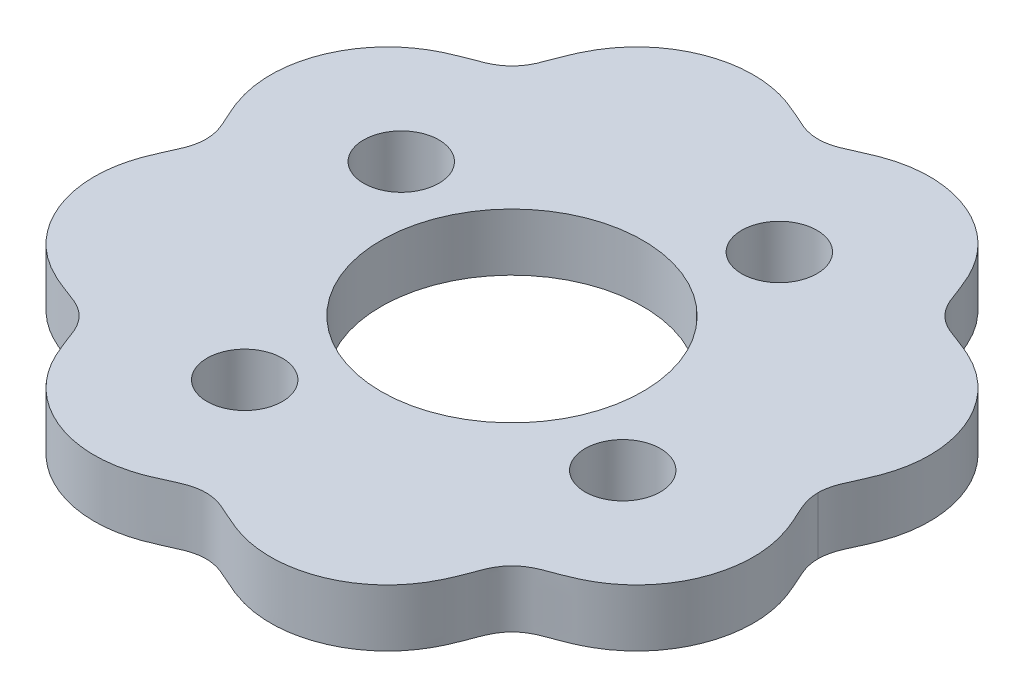
from build123d import *

# Parameters (mm, degrees)
BOSS_EXTRUDE1_DEPTH = 7
SKETCH3_R           = 16
SKETCH3_R_2         = 4.5
CUT_EXTRUDE1_DEPTH  = 7
CUT_EXTRUDE2_DEPTH  = 7
SKETCH5_R           = 4.6
SKETCH5_R_2         = 4.5
CUT_EXTRUDE3_DEPTH  = 7


with BuildPart() as part:
    # Sketch2 → Boss-Extrude1 (new body)
    with BuildSketch(Plane(origin=(0, 0, 0), x_dir=(1, 0, 0), z_dir=(0, 1, 0))):
        with BuildLine():
            add(Edge.make_bspline(
                [(37.500000178, 0), (37.500001348, -0.153650042), (37.516723117, -0.585734713), (37.60134551, -1.155885936), (37.799451038, -1.845132779), (38.055257689, -2.50061582), (38.284413658, -3.01884437), (38.547573645, -3.586057627), (38.834335204, -4.207231283), (39.213023964, -5.071386775), (39.642902809, -6.195484546), (40.034770345, -7.545626157), (40.309114863, -9.129071904), (40.402480997, -10.733442687), (40.292330227, -12.739242447), (39.800709206, -15.115411572), (38.875008006, -17.372282299), (37.550500891, -19.416826213), (36.201869244, -20.937061223), (34.991297456, -22.022332107), (33.664442598, -22.961820777), (32.418877976, -23.648429526), (31.307176029, -24.144813461), (30.415442254, -24.492540623), (29.760772524, -24.733252947), (29.159260868, -24.953726937), (28.615153012, -25.166050116), (27.968227921, -25.455751973), (27.242450172, -25.869161743), (26.486758972, -26.478530797), (25.788934233, -27.338578085), (25.333439826, -28.199550113), (25.02084924, -28.978917238), (24.756184284, -29.69717513), (24.520071708, -30.342148991), (24.176798097, -31.229963234), (23.685673389, -32.343953643), (23.006023391, -33.593318677), (22.074382722, -34.925670234), (20.99628636, -36.142619362), (19.483992231, -37.500137581), (17.436434568, -38.843473511), (15.165772212, -39.787003781), (12.765640508, -40.290729235), (10.727941267, -40.403684264), (9.098120231, -40.306732746), (7.490297544, -40.023060283), (6.12050869, -39.618509318), (4.980859334, -39.175936442), (3.981084292, -38.733166074), (3.107747272, -38.323212218), (2.16284156, -37.896233325), (1.102684883, -37.568652762), (-4e-09, -37.451718585), (-1.102684874, -37.568652759), (-2.162841573, -37.896233332), (-3.107747248, -38.323212203), (-3.981084328, -38.733166098), (-4.980859269, -39.175936398), (-6.120508811, -39.6185094), (-7.490297349, -40.023060149), (-9.098120503, -40.306732933), (-10.727940878, -40.403683996), (-12.765641194, -40.290729708), (-15.165770912, -39.787002885), (-17.436436591, -38.843474905), (-19.48398961, -37.500135775), (-20.996290415, -36.142622155), (-22.074374394, -34.925664496), (-23.006039129, -33.59332952), (-23.685647307, -32.343935674), (-24.176838549, -31.229991103), (-24.570729586, -30.210893235), (-24.899588849, -29.300399238), (-25.267416458, -28.324512461), (-25.788900803, -27.338555053), (-26.486780724, -26.478545782), (-27.242436428, -25.869152274), (-27.968236735, -25.455758045), (-28.615147496, -25.166046316), (-29.159264206, -24.953729236), (-29.760770668, -24.733251668), (-30.415443148, -24.492541238), (-31.307175489, -24.144813089), (-32.41887831, -23.648429756), (-33.6644424, -22.96182064), (-34.99129756, -22.022332179), (-36.201869193, -20.937061188), (-37.550500924, -19.416826235), (-38.875007981, -17.372282282), (-39.800709222, -15.115411584), (-40.292330218, -12.739242441), (-40.402481002, -10.733442691), (-40.309114859, -9.129071901), (-40.034770347, -7.545626159), (-39.642902807, -6.195484545), (-39.213023965, -5.071386776), (-38.834335204, -4.207231283), (-38.547573646, -3.586057627), (-38.284413658, -3.01884437), (-38.055257689, -2.50061582), (-37.799451038, -1.845132779), (-37.60134551, -1.155885936), (-37.516723117, -0.585734713), (-37.500001348, -0.153650042), (-37.500000178, 0)],
                knots=[0.119900748, 0.119900748, 0.119900748, 0.119900748, 0.119900748, 0.123359436, 0.129627259, 0.132815238, 0.136003217, 0.139191195, 0.142379174, 0.14689104, 0.151402906, 0.160426638, 0.169450869, 0.1784751, 0.187499512, 0.196523925, 0.214572937, 0.232831382, 0.241960244, 0.251089107, 0.260218415, 0.269347723, 0.278476117, 0.283040314, 0.287604511, 0.290890352, 0.294176194, 0.297462035, 0.300747877, 0.306837966, 0.312927068, 0.319161334, 0.325493528, 0.328659626, 0.331825723, 0.336390118, 0.340954513, 0.350083302, 0.35921236, 0.368341418, 0.377470301, 0.386599184, 0.404857643, 0.423193135, 0.432360527, 0.441527919, 0.450695565, 0.459863212, 0.469030281, 0.473613816, 0.47819735, 0.484472892, 0.490748434, 0.496943117, 0.503056883, 0.509251566, 0.515527108, 0.52180265, 0.526386184, 0.530969719, 0.540136788, 0.549304435, 0.558472081, 0.567639473, 0.576806865, 0.595142357, 0.613400816, 0.622529699, 0.631658582, 0.64078764, 0.649916698, 0.659045487, 0.663609882, 0.668174277, 0.674506472, 0.680838666, 0.687072932, 0.693162034, 0.699252123, 0.702537965, 0.705823806, 0.709109648, 0.712395489, 0.716959686, 0.721523883, 0.730652277, 0.739781585, 0.748910893, 0.758039756, 0.767168618, 0.785427063, 0.803476075, 0.812500488, 0.8215249, 0.830549131, 0.839573362, 0.848597094, 0.85310896, 0.857620826, 0.860808805, 0.863996783, 0.867184762, 0.870372741, 0.876640564, 0.880099252, 0.880099252, 0.880099252, 0.880099252, 0.880099252], degree=4))
            add(Edge.make_bspline(
                [(37.500000178, 0), (37.500001348, 0.153650042), (37.516723117, 0.585734713), (37.60134551, 1.155885936), (37.799451038, 1.845132779), (38.055257689, 2.50061582), (38.284413658, 3.018844371), (38.547573645, 3.586057627), (38.834335204, 4.207231284), (39.213023964, 5.071386775), (39.642902809, 6.195484546), (40.034770345, 7.545626157), (40.309114863, 9.129071904), (40.402480997, 10.733442688), (40.292330227, 12.739242447), (39.800709205, 15.115411572), (38.875008006, 17.3722823), (37.550500891, 19.416826213), (36.201869244, 20.937061223), (34.991297456, 22.022332107), (33.664442598, 22.961820777), (32.418877976, 23.648429526), (31.307176029, 24.144813461), (30.415442254, 24.492540623), (29.760772524, 24.733252947), (29.159260868, 24.953726937), (28.615153012, 25.166050117), (27.968227921, 25.455751974), (27.242450172, 25.869161744), (26.486758972, 26.478530797), (25.788934233, 27.338578085), (25.333439826, 28.199550113), (25.02084924, 28.978917238), (24.756184284, 29.69717513), (24.520071708, 30.342148991), (24.176798097, 31.229963234), (23.685673389, 32.343953643), (23.006023391, 33.593318677), (22.074382722, 34.925670234), (20.99628636, 36.142619362), (19.483992231, 37.500137582), (17.436434568, 38.843473511), (15.165772212, 39.787003781), (12.765640508, 40.290729235), (10.727941267, 40.403684265), (9.098120231, 40.306732746), (7.490297544, 40.023060283), (6.12050869, 39.618509318), (4.980859334, 39.175936443), (3.981084292, 38.733166074), (3.107747271, 38.323212218), (2.162841559, 37.896233325), (1.102684882, 37.568652762), (-4e-09, 37.451718586), (-1.102684874, 37.568652759), (-2.162841573, 37.896233332), (-3.107747248, 38.323212203), (-3.981084328, 38.733166098), (-4.980859269, 39.175936399), (-6.120508811, 39.6185094), (-7.490297349, 40.023060149), (-9.098120503, 40.306732933), (-10.727940878, 40.403683996), (-12.765641194, 40.290729708), (-15.165770912, 39.787002885), (-17.436436591, 38.843474905), (-19.48398961, 37.500135776), (-20.996290415, 36.142622155), (-22.074374394, 34.925664496), (-23.006039129, 33.59332952), (-23.685647307, 32.343935674), (-24.176838549, 31.229991103), (-24.570729586, 30.210893235), (-24.899588849, 29.300399238), (-25.267416458, 28.324512461), (-25.788900803, 27.338555053), (-26.486780724, 26.478545782), (-27.242436428, 25.869152274), (-27.968236735, 25.455758045), (-28.615147496, 25.166046316), (-29.159264206, 24.953729236), (-29.760770668, 24.733251668), (-30.415443148, 24.492541238), (-31.307175489, 24.144813089), (-32.418878311, 23.648429756), (-33.6644424, 22.96182064), (-34.99129756, 22.022332179), (-36.201869193, 20.937061188), (-37.550500924, 19.416826235), (-38.875007981, 17.372282282), (-39.800709222, 15.115411584), (-40.292330218, 12.739242441), (-40.402481002, 10.733442691), (-40.309114859, 9.129071901), (-40.034770347, 7.545626159), (-39.642902807, 6.195484545), (-39.213023965, 5.071386776), (-38.834335204, 4.207231283), (-38.547573646, 3.586057627), (-38.284413658, 3.01884437), (-38.055257689, 2.50061582), (-37.799451038, 1.845132779), (-37.60134551, 1.155885936), (-37.516723117, 0.585734713), (-37.500001348, 0.153650042), (-37.500000178, 0)],
                knots=[0.119900748, 0.119900748, 0.119900748, 0.119900748, 0.119900748, 0.123359436, 0.129627259, 0.132815238, 0.136003217, 0.139191195, 0.142379174, 0.14689104, 0.151402906, 0.160426638, 0.169450869, 0.1784751, 0.187499512, 0.196523925, 0.214572937, 0.232831382, 0.241960244, 0.251089107, 0.260218415, 0.269347723, 0.278476117, 0.283040314, 0.287604511, 0.290890352, 0.294176194, 0.297462035, 0.300747877, 0.306837966, 0.312927068, 0.319161334, 0.325493528, 0.328659626, 0.331825723, 0.336390118, 0.340954513, 0.350083302, 0.35921236, 0.368341418, 0.377470301, 0.386599184, 0.404857643, 0.423193135, 0.432360527, 0.441527919, 0.450695565, 0.459863212, 0.469030281, 0.473613816, 0.47819735, 0.484472892, 0.490748434, 0.496943117, 0.503056883, 0.509251566, 0.515527108, 0.52180265, 0.526386184, 0.530969719, 0.540136788, 0.549304435, 0.558472081, 0.567639473, 0.576806865, 0.595142357, 0.613400816, 0.622529699, 0.631658582, 0.64078764, 0.649916698, 0.659045487, 0.663609882, 0.668174277, 0.674506472, 0.680838666, 0.687072932, 0.693162034, 0.699252123, 0.702537965, 0.705823806, 0.709109648, 0.712395489, 0.716959686, 0.721523883, 0.730652277, 0.739781585, 0.748910893, 0.758039756, 0.767168618, 0.785427063, 0.803476075, 0.812500488, 0.8215249, 0.830549131, 0.839573362, 0.848597094, 0.85310896, 0.857620826, 0.860808805, 0.863996783, 0.867184762, 0.870372741, 0.876640564, 0.880099252, 0.880099252, 0.880099252, 0.880099252, 0.880099252], degree=4))
        make_face()
    extrude(amount=BOSS_EXTRUDE1_DEPTH)

    # Sketch3 → Cut-Extrude1 (cut)
    with BuildSketch(Plane(origin=(0, 7, 0), x_dir=(1, 0, 0), z_dir=(0, 1, 0))):
        with Locations(Location((0, 0, 0), (0, 0, 270))):
            Circle(SKETCH3_R)
        with Locations(Location((23.096990508, -9.567080508, 0), (0, 0, 270))):
            Circle(SKETCH3_R_2)
        with Locations(Location((-9.567080508, -23.096990508, 0), (0, 0, 270))):
            Circle(SKETCH3_R_2)
        with Locations(Location((-23.096990508, 9.567080508, 0), (0, 0, 270))):
            Circle(SKETCH3_R_2)
        with Locations(Location((9.567080508, 23.096990508, 0), (0, 0, 270))):
            Circle(SKETCH3_R_2)
    extrude(amount=-CUT_EXTRUDE1_DEPTH, mode=Mode.SUBTRACT)

    # Sketch4 → Cut-Extrude2 (cut)
    with BuildSketch(Plane.XZ):
        with BuildLine():
            add(Edge.make_bspline(
                [(37.600000178, -7.62e-07), (37.600005173, 0.655543434), (37.727246294, 1.285292151), (38.148613998, 2.510955716), (38.436102386, 3.105161712), (38.985288009, 4.298020071), (39.25007046, 4.89726072), (39.708668965, 6.116079685), (39.903757651, 6.735293288), (40.210295805, 7.997689961), (40.322350501, 8.640699582), (40.423535505, 9.624385479), (40.446121573, 9.955473947), (40.468001099, 10.624326117), (40.467132418, 10.962202585), (40.404154621, 12.633267942), (40.171207894, 13.940406977), (39.653355411, 15.537439287), (39.53840444, 15.854111127), (39.288969244, 16.474140513), (39.154125231, 16.778652945), (38.719700075, 17.675947604), (38.390382228, 18.252572177), (37.651152224, 19.362029827), (37.237638616, 19.898295795), (36.350233191, 20.896017325), (35.875310831, 21.360215751), (34.86364689, 22.219976378), (34.326804277, 22.615426405), (33.190062483, 23.336316439), (32.60031159, 23.654622118), (31.388326763, 24.220411489), (30.765097907, 24.46709151), (29.82114865, 24.818166657), (29.504943402, 24.932139267), (28.877738152, 25.170299043), (28.566999308, 25.294998698), (27.963605007, 25.579884088), (27.671054253, 25.740275293), (27.252684988, 26.021005802), (27.116605528, 26.121209448), (26.852062793, 26.336562421), (26.722665603, 26.452707189), (26.356285675, 26.816433091), (26.140022275, 27.07952826), (25.757076777, 27.642229352), (25.590264073, 27.942868865), (25.294527671, 28.566753755), (25.165960187, 28.88852981), (24.920043824, 29.537797739), (24.802144961, 29.865009399), (24.438030972, 30.841336769), (24.180422964, 31.484647868), (23.587360405, 32.731607676), (23.25304691, 33.335837747), (22.68412998, 34.207819134), (22.483367041, 34.492811998), (22.058499308, 35.050905177), (21.833191694, 35.325295896), (20.664259321, 36.645203337), (19.595247471, 37.543032975), (18.094714825, 38.471318944), (17.786587006, 38.646710961), (17.16359185, 38.972125312), (16.847523582, 39.122917749), (15.885856655, 39.540202403), (15.22687273, 39.771802315), (13.87261568, 40.140404542), (13.173528063, 40.277153852), (11.782084832, 40.445055871), (11.084941822, 40.478018046), (10.037091008, 40.450827085), (9.687449992, 40.428942237), (8.987437718, 40.358977003), (8.635705971, 40.310604168), (7.593654297, 40.127900907), (6.914470746, 39.955864647), (5.583322024, 39.523679687), (4.931756901, 39.262235939), (3.965705794, 38.833500579), (3.645753433, 38.684780069), (3.005286176, 38.389391142), (2.68471998, 38.242500373), (2.031257787, 37.978515382), (1.696459255, 37.861664089), (1.010367338, 37.687113144), (0.664117722, 37.630625011), (-0.035741815, 37.588381702), (-0.393307149, 37.603289467), (-1.091614861, 37.702477523), (-1.432710085, 37.785974847), (-2.438166569, 38.111475608), (-3.083100648, 38.4262163), (-4.379716439, 39.022574646), (-5.031837648, 39.307994347), (-7.027326378, 40.033339578), (-8.409077537, 40.344832204), (-10.21846616, 40.459155192), (-10.584845551, 40.468254818), (-11.309896166, 40.458614645), (-11.670551949, 40.440062156), (-12.747048154, 40.344216969), (-13.457448828, 40.226967163), (-14.86370086, 39.885597037), (-15.562456431, 39.659406696), (-16.900219943, 39.113501325), (-17.544817785, 38.792942013), (-18.475327327, 38.240768871), (-18.779405529, 38.044768985), (-19.375039214, 37.628219448), (-19.66690843, 37.407240978), (-20.508686277, 36.71835058), (-21.030063876, 36.221285174), (-21.994225641, 35.152514509), (-22.437469885, 34.579790659), (-23.240332907, 33.36091442), (-23.59210782, 32.725699772), (-24.21279859, 31.412258693), (-24.48008686, 30.732790864), (-24.860030442, 29.706920221), (-24.983492598, 29.36369043), (-25.247586749, 28.684091392), (-25.389357526, 28.348177168), (-25.724856238, 27.697109221), (-25.915605335, 27.388429681), (-26.246180912, 26.958382913), (-26.363678476, 26.820434816), (-26.614172398, 26.555996288), (-26.747939886, 26.428953409), (-27.16370152, 26.07353653), (-27.462129542, 25.868655053), (-28.093141458, 25.510419531), (-28.426355493, 25.357147124), (-29.105776125, 25.079258707), (-29.452106763, 24.953195271), (-30.14359664, 24.698789273), (-30.488894925, 24.570717247), (-31.514041104, 24.165588103), (-32.18271169, 23.866783955), (-33.471088526, 23.173908637), (-34.091529712, 22.781267386), (-34.981950491, 22.114010966), (-35.27336833, 21.877454907), (-35.835818537, 21.382587609), (-36.105593168, 21.125601748), (-36.881608687, 20.326857649), (-37.354731828, 19.757471925), (-37.998824092, 18.848674808), (-38.202543253, 18.53658415), (-38.587532455, 17.893675331), (-38.767696262, 17.564496513), (-39.266089097, 16.565119922), (-39.545090734, 15.87888218), (-39.884673796, 14.819909921), (-39.984652036, 14.461959629), (-40.157555715, 13.735907091), (-40.230632334, 13.366355214), (-40.521494844, 11.52176003), (-40.525439669, 10.040086765), (-40.178392425, 7.814366715), (-40.005185357, 7.088457072), (-39.55623337, 5.665152555), (-39.278423148, 4.967801646), (-38.820443408, 3.936514094), (-38.661078223, 3.595018652), (-38.346103028, 2.91075813), (-38.190776414, 2.567897234), (-37.919747303, 1.868778393), (-37.804834772, 1.512253359), (-37.645169711, 0.77548196), (-37.60000319, 0.395375566), (-37.600000178, -7.62e-07)],
                knots=[0, 0, 0, 0, 0.015625, 0.015625, 0.03125, 0.03125, 0.046875, 0.046875, 0.0625, 0.0625, 0.078125, 0.078125, 0.0859375, 0.0859375, 0.09375, 0.09375, 0.125, 0.125, 0.1328125, 0.1328125, 0.140625, 0.140625, 0.15625, 0.15625, 0.171875, 0.171875, 0.1875, 0.1875, 0.203125, 0.203125, 0.21875, 0.21875, 0.234375, 0.234375, 0.2421875, 0.2421875, 0.25, 0.25, 0.2578125, 0.2578125, 0.26171875, 0.26171875, 0.265625, 0.265625, 0.2734375, 0.2734375, 0.28125, 0.28125, 0.2890625, 0.2890625, 0.296875, 0.296875, 0.3125, 0.3125, 0.328125, 0.328125, 0.3359375, 0.3359375, 0.34375, 0.34375, 0.375, 0.375, 0.3828125, 0.3828125, 0.390625, 0.390625, 0.40625, 0.40625, 0.421875, 0.421875, 0.4375, 0.4375, 0.4453125, 0.4453125, 0.453125, 0.453125, 0.46875, 0.46875, 0.484375, 0.484375, 0.4921875, 0.4921875, 0.5, 0.5, 0.5078125, 0.5078125, 0.515625, 0.515625, 0.5234375, 0.5234375, 0.53125, 0.53125, 0.546875, 0.546875, 0.5625, 0.5625, 0.59375, 0.59375, 0.6015625, 0.6015625, 0.609375, 0.609375, 0.625, 0.625, 0.640625, 0.640625, 0.65625, 0.65625, 0.6640625, 0.6640625, 0.671875, 0.671875, 0.6875, 0.6875, 0.703125, 0.703125, 0.71875, 0.71875, 0.734375, 0.734375, 0.7421875, 0.7421875, 0.75, 0.75, 0.7578125, 0.7578125, 0.76171875, 0.76171875, 0.765625, 0.765625, 0.7734375, 0.7734375, 0.78125, 0.78125, 0.7890625, 0.7890625, 0.796875, 0.796875, 0.8125, 0.8125, 0.828125, 0.828125, 0.8359375, 0.8359375, 0.84375, 0.84375, 0.859375, 0.859375, 0.8671875, 0.8671875, 0.875, 0.875, 0.890625, 0.890625, 0.8984375, 0.8984375, 0.90625, 0.90625, 0.9375, 0.9375, 0.953125, 0.953125, 0.96875, 0.96875, 0.9765625, 0.9765625, 0.984375, 0.984375, 0.9921875, 0.9921875, 1, 1, 1, 1], degree=3))
            add(Edge.make_bspline(
                [(-37.600000178, -7.62e-07), (-37.600005365, -0.655543542), (-37.727246103, -1.285290917), (-38.148612441, -2.510951863), (-38.436099991, -3.105156631), (-38.985284513, -4.298012358), (-39.250066616, -4.89725163), (-39.708664877, -6.116067692), (-39.903753667, -6.73527977), (-40.210292449, -7.99767325), (-40.32234767, -8.640681203), (-40.423533815, -9.624364479), (-40.446120322, -9.955452053), (-40.46800086, -10.624302393), (-40.467132754, -10.962178241), (-40.40415798, -12.633240584), (-40.171214287, -13.940377214), (-39.653366826, -15.537406602), (-39.538416782, -15.85407826), (-39.288983549, -16.474107134), (-39.154140553, -16.778619323), (-38.719718579, -17.675913303), (-38.390403025, -18.252537492), (-37.651178052, -19.361994563), (-37.237667074, -19.898260544), (-36.350266394, -20.895983208), (-35.875346564, -21.360182341), (-34.863687943, -22.2199446), (-34.326848086, -22.615395516), (-33.190112346, -23.336287858), (-32.600363206, -23.654595622), (-31.388382903, -24.22038754), (-30.765156596, -24.467069397), (-29.821209522, -24.818143642), (-29.505006095, -24.932118144), (-28.877800637, -25.170273989), (-28.567061614, -25.294971441), (-27.963668625, -25.579855149), (-27.671114267, -25.740236871), (-27.252743788, -26.020960746), (-27.116664699, -26.121163599), (-26.852122749, -26.336514839), (-26.722725603, -26.452657923), (-26.356336634, -26.81637785), (-26.140060384, -27.079462774), (-25.757116549, -27.642161336), (-25.590319291, -27.94280622), (-25.294558985, -28.566675929), (-25.165952551, -28.888431272), (-24.920089484, -29.537724991), (-24.802198315, -29.864940055), (-24.438006248, -30.841225751), (-24.180470786, -31.484572065), (-23.587393761, -32.73151845), (-23.253098655, -33.335753624), (-22.684194198, -34.207732752), (-22.483432874, -34.492723202), (-22.058571, -35.050812128), (-21.833267652, -35.325202016), (-20.664333278, -36.645139912), (-19.59532023, -37.542975085), (-18.094804652, -38.471266211), (-17.786672933, -38.646663689), (-17.163673089, -38.97208582), (-16.847603026, -39.122881412), (-15.885932573, -39.540174), (-15.226948812, -39.771777283), (-13.872698563, -40.140385932), (-13.173607801, -40.277140714), (-11.782152302, -40.445051479), (-11.085006279, -40.478016471), (-10.037155717, -40.4508303), (-9.687515582, -40.428947116), (-8.987506709, -40.358985611), (-8.635775999, -40.310614821), (-7.593711021, -40.127914145), (-6.914521606, -39.955878883), (-5.583365941, -39.523696233), (-4.931799795, -39.262253844), (-3.965749214, -38.833520414), (-3.645796202, -38.68479995), (-3.005328478, -38.389410498), (-2.684762254, -38.242519007), (-2.031301111, -37.978531327), (-1.696505827, -37.861678656), (-1.0104107, -37.687121458), (-0.664160249, -37.630630436), (0.035699138, -37.588381419), (0.393263445, -37.60328603), (1.091574708, -37.702469051), (1.432671198, -37.785964254), (2.438130273, -38.111459865), (3.083065306, -38.426199691), (4.379682535, -39.022559402), (5.031804119, -39.307980643), (7.027293072, -40.033330486), (8.409043202, -40.344826141), (10.218428372, -40.459153805), (10.584809331, -40.468254499), (11.309863139, -40.458615982), (11.670520298, -40.44006415), (12.747020041, -40.344220841), (13.45742231, -40.226972298), (14.863675994, -39.885604677), (15.562434158, -39.659414723), (16.900203227, -39.113508859), (17.54480309, -38.792949489), (18.475314811, -38.240777102), (18.77939358, -38.044777578), (19.37502788, -37.628228605), (19.666898392, -37.407249287), (20.508679462, -36.718355349), (21.030059241, -36.221288774), (21.994226396, -35.15251904), (22.437464112, -34.579791894), (23.240331243, -33.360911439), (23.592120209, -32.725702161), (24.212786306, -31.412246514), (24.480142321, -30.732808794), (24.859989324, -29.706902419), (24.983506975, -29.363695738), (25.24761708, -28.684105036), (25.389343463, -28.348174104), (25.724844079, -27.697109244), (25.91561204, -27.388436226), (26.246183235, -26.958387021), (26.363676717, -26.820436861), (26.614164843, -26.55599741), (26.747931978, -26.428954455), (27.163699633, -26.073538663), (27.462129817, -25.868658916), (28.093136327, -25.510418282), (28.426351029, -25.357151397), (29.10577059, -25.079261698), (29.452100801, -24.953197072), (30.143591533, -24.698792161), (30.488889356, -24.570718998), (31.514035603, -24.165590501), (32.18270537, -23.866786785), (33.471078721, -23.173914326), (34.091517278, -22.781275489), (34.981932843, -22.114024813), (35.273346468, -21.877473279), (35.83580515, -21.382600187), (36.105583092, -21.125611724), (36.88160624, -20.326861011), (37.354731418, -19.757472462), (37.998823996, -18.848674943), (38.202542797, -18.536584789), (38.587530614, -17.893678518), (38.767698421, -17.564492662), (39.266095867, -16.565105414), (39.545098068, -15.878862979), (39.884680234, -14.819888), (39.98465788, -14.461937524), (40.157560102, -13.735886218), (40.230636486, -13.366333326), (40.521499132, -11.52171509), (40.525439935, -10.040058501), (40.178382099, -7.81431547), (40.005171366, -7.08840487), (39.556217128, -5.665108908), (39.278408813, -4.96776748), (38.820430227, -3.936485358), (38.661065563, -3.594991484), (38.346092068, -2.910733985), (38.190766712, -2.567874525), (37.919740862, -1.868759462), (37.804830308, -1.5122368), (37.64516852, -0.775472421), (37.600003306, -0.395370659), (37.600000178, -7.62e-07)],
                knots=[0, 0, 0, 0, 0.015625, 0.015625, 0.03125, 0.03125, 0.046875, 0.046875, 0.0625, 0.0625, 0.078125, 0.078125, 0.0859375, 0.0859375, 0.09375, 0.09375, 0.125, 0.125, 0.1328125, 0.1328125, 0.140625, 0.140625, 0.15625, 0.15625, 0.171875, 0.171875, 0.1875, 0.1875, 0.203125, 0.203125, 0.21875, 0.21875, 0.234375, 0.234375, 0.2421875, 0.2421875, 0.25, 0.25, 0.2578125, 0.2578125, 0.26171875, 0.26171875, 0.265625, 0.265625, 0.2734375, 0.2734375, 0.28125, 0.28125, 0.2890625, 0.2890625, 0.296875, 0.296875, 0.3125, 0.3125, 0.328125, 0.328125, 0.3359375, 0.3359375, 0.34375, 0.34375, 0.375, 0.375, 0.3828125, 0.3828125, 0.390625, 0.390625, 0.40625, 0.40625, 0.421875, 0.421875, 0.4375, 0.4375, 0.4453125, 0.4453125, 0.453125, 0.453125, 0.46875, 0.46875, 0.484375, 0.484375, 0.4921875, 0.4921875, 0.5, 0.5, 0.5078125, 0.5078125, 0.515625, 0.515625, 0.5234375, 0.5234375, 0.53125, 0.53125, 0.546875, 0.546875, 0.5625, 0.5625, 0.59375, 0.59375, 0.6015625, 0.6015625, 0.609375, 0.609375, 0.625, 0.625, 0.640625, 0.640625, 0.65625, 0.65625, 0.6640625, 0.6640625, 0.671875, 0.671875, 0.6875, 0.6875, 0.703125, 0.703125, 0.71875, 0.71875, 0.734375, 0.734375, 0.7421875, 0.7421875, 0.75, 0.75, 0.7578125, 0.7578125, 0.76171875, 0.76171875, 0.765625, 0.765625, 0.7734375, 0.7734375, 0.78125, 0.78125, 0.7890625, 0.7890625, 0.796875, 0.796875, 0.8125, 0.8125, 0.828125, 0.828125, 0.8359375, 0.8359375, 0.84375, 0.84375, 0.859375, 0.859375, 0.8671875, 0.8671875, 0.875, 0.875, 0.890625, 0.890625, 0.8984375, 0.8984375, 0.90625, 0.90625, 0.9375, 0.9375, 0.953125, 0.953125, 0.96875, 0.96875, 0.9765625, 0.9765625, 0.984375, 0.984375, 0.9921875, 0.9921875, 1, 1, 1, 1], degree=3))
        make_face()
        with BuildLine():
            add(Edge.make_bspline(
                [(-37.400000178, -7.62e-07), (-37.400005396, -0.684782698), (-37.533286812, -1.339126969), (-37.971679468, -2.608572955), (-38.271031887, -3.223687862), (-38.838782813, -4.459321056), (-39.110829218, -5.081035786), (-39.576516793, -6.350302799), (-39.771486208, -6.997417375), (-39.99451977, -7.990965997), (-40.05744554, -8.32591179), (-40.159277451, -9.003718774), (-40.198243708, -9.348068689), (-40.276348787, -10.376291039), (-40.277850295, -11.058613953), (-40.183363174, -12.417170278), (-40.087400677, -13.09340532), (-39.868679486, -14.103087076), (-39.783319969, -14.438056838), (-39.59042803, -15.095859731), (-39.48263265, -15.419986744), (-39.12581691, -16.378304723), (-38.84355357, -16.998511139), (-38.18898741, -18.201046447), (-37.813942623, -18.785938211), (-36.99479459, -19.880772476), (-36.548792021, -20.3951967), (-35.82505198, -21.117259116), (-35.574649061, -21.349653891), (-35.055120881, -21.797486837), (-34.784834447, -22.013734698), (-33.955457842, -22.628774327), (-33.377932351, -22.994173963), (-32.178507652, -23.644500379), (-31.556012432, -23.928346277), (-30.599954922, -24.313646888), (-30.277766915, -24.435469134), (-29.63193924, -24.674412462), (-29.307914732, -24.791237357), (-28.665975068, -25.039445958), (-28.348334449, -25.171483897), (-27.730650697, -25.477495242), (-27.428442172, -25.653477659), (-26.868187016, -26.052195413), (-26.608446968, -26.274990584), (-26.132348562, -26.770449944), (-25.915011101, -27.045671206), (-25.537300003, -27.621849778), (-25.211954314, -28.227622351), (-24.957163129, -28.873297255), (-24.712468595, -29.523337971), (-24.594494769, -29.850537878), (-24.350947641, -30.501150415), (-24.225635279, -30.824693088), (-23.827233466, -31.784125578), (-23.530975212, -32.408468985), (-22.85017451, -33.613158464), (-22.466684316, -34.194028938), (-21.603070624, -35.307611687), (-21.132656874, -35.827766741), (-20.125777301, -36.788678712), (-19.58809831, -37.231085461), (-18.729810076, -37.837165058), (-18.433783397, -38.030294514), (-17.831109532, -38.392526944), (-17.524735048, -38.561626533), (-16.590894916, -39.033819984), (-15.94879626, -39.302008124), (-14.956328158, -39.634349833), (-14.62059786, -39.733423772), (-13.939053544, -39.907517841), (-13.593789054, -39.982265156), (-12.559820995, -40.166656604), (-11.8674468, -40.238150222), (-10.476620435, -40.279047706), (-9.776594528, -40.248219137), (-8.376672719, -40.079878197), (-7.6911699, -39.944036586), (-6.346580769, -39.577944521), (-5.687826974, -39.346505701), (-4.714282748, -38.947217509), (-4.392074109, -38.805607303), (-3.751381616, -38.514617754), (-3.432753161, -38.36487402), (-2.792036452, -38.073944369), (-2.469758023, -37.933228846), (-1.809689185, -37.690166697), (-1.469545671, -37.587394011), (-0.775270684, -37.444719036), (-0.426808853, -37.405549185), (0.09799503, -37.398073089), (0.273279678, -37.404082921), (0.624554464, -37.433238656), (0.801546504, -37.456601741), (1.325077342, -37.550476286), (1.66339974, -37.644392915), (2.325478044, -37.874889644), (2.649203286, -38.011559554), (3.2917588, -38.299236139), (3.610903594, -38.449412827), (4.251521045, -38.742650641), (4.572846355, -38.886011923), (5.544255336, -39.292276704), (6.202012957, -39.530589187), (7.547443713, -39.911350487), (8.23472814, -40.055044912), (9.29000814, -40.1925467), (9.6461978, -40.225289386), (10.353430535, -40.263373674), (10.706125957, -40.268992909), (11.761511932, -40.246493479), (12.461516923, -40.179232376), (13.854352603, -39.940143682), (14.550375034, -39.766491039), (15.891060177, -39.324781027), (16.54105071, -39.056315832), (17.485676754, -38.582596479), (17.795469882, -38.412801026), (18.404639621, -38.048842421), (18.704595381, -37.854141796), (20.153495888, -36.834999859), (21.171952529, -35.866147091), (22.481006654, -34.174225043), (22.869476355, -33.583405835), (23.558708325, -32.354697774), (23.85844027, -31.71587745), (24.262128264, -30.732621462), (24.389246226, -30.40070898), (24.63692668, -29.734586129), (24.757334626, -29.400089263), (25.010944677, -28.736446272), (25.144925475, -28.40762581), (25.456484559, -27.76821812), (25.635968748, -27.455381634), (26.045030072, -26.876026075), (26.27464328, -26.60771406), (26.78766381, -26.116912824), (27.072701132, -25.894410351), (27.669080144, -25.509607724), (27.983173611, -25.344568468), (28.632231292, -25.05039715), (28.966685454, -24.920989432), (29.638938436, -24.670249034), (29.976782523, -24.548266438), (30.64756686, -24.294629444), (30.980672328, -24.163300906), (31.967133586, -23.74396118), (32.607250079, -23.429838227), (33.839298887, -22.706559031), (34.431789218, -22.298503359), (35.564278995, -21.378864634), (36.089123563, -20.879663569), (37.054138637, -19.811388989), (37.495362926, -19.241503897), (38.094449592, -18.33234027), (38.284134766, -18.019119802), (38.63632304, -17.38438218), (38.799558141, -17.061911954), (39.251551291, -16.079540171), (39.502830049, -15.404769892), (39.904118336, -14.015053973), (40.053893907, -13.295882593), (40.239714572, -11.86329121), (40.277796435, -11.144821741), (40.252251475, -10.06384002), (40.229900275, -9.702964217), (40.156824934, -8.980087712), (40.105861118, -8.617487518), (39.913081657, -7.546146616), (39.730522673, -6.848033091), (39.27169922, -5.47974765), (38.993704358, -4.80981043), (38.544415856, -3.815458247), (38.389526399, -3.485950632), (38.087864961, -2.823858685), (37.941658479, -2.491060014), (37.689775713, -1.81010075), (37.58446697, -1.461800851), (37.439017725, -0.740500718), (37.400003001, -0.370486849), (37.400000178, -7.62e-07)],
                knots=[0, 0, 0, 0, 0.015625, 0.015625, 0.03125, 0.03125, 0.046875, 0.046875, 0.0625, 0.0625, 0.0703125, 0.0703125, 0.078125, 0.078125, 0.09375, 0.09375, 0.109375, 0.109375, 0.1171875, 0.1171875, 0.125, 0.125, 0.140625, 0.140625, 0.15625, 0.15625, 0.171875, 0.171875, 0.1796875, 0.1796875, 0.1875, 0.1875, 0.203125, 0.203125, 0.21875, 0.21875, 0.2265625, 0.2265625, 0.234375, 0.234375, 0.2421875, 0.2421875, 0.25, 0.25, 0.2578125, 0.2578125, 0.265625, 0.265625, 0.2734375, 0.28125, 0.28125, 0.2890625, 0.2890625, 0.296875, 0.296875, 0.3125, 0.3125, 0.328125, 0.328125, 0.34375, 0.34375, 0.359375, 0.359375, 0.3671875, 0.3671875, 0.375, 0.375, 0.390625, 0.390625, 0.3984375, 0.3984375, 0.40625, 0.40625, 0.421875, 0.421875, 0.4375, 0.4375, 0.453125, 0.453125, 0.46875, 0.46875, 0.4765625, 0.4765625, 0.484375, 0.484375, 0.4921875, 0.4921875, 0.5, 0.5, 0.5078125, 0.5078125, 0.51171875, 0.51171875, 0.515625, 0.515625, 0.5234375, 0.5234375, 0.53125, 0.53125, 0.5390625, 0.5390625, 0.546875, 0.546875, 0.5625, 0.5625, 0.578125, 0.578125, 0.5859375, 0.5859375, 0.59375, 0.59375, 0.609375, 0.609375, 0.625, 0.625, 0.640625, 0.640625, 0.6484375, 0.6484375, 0.65625, 0.65625, 0.6875, 0.6875, 0.703125, 0.703125, 0.71875, 0.71875, 0.7265625, 0.7265625, 0.734375, 0.734375, 0.7421875, 0.7421875, 0.75, 0.75, 0.7578125, 0.7578125, 0.765625, 0.765625, 0.7734375, 0.7734375, 0.78125, 0.78125, 0.7890625, 0.7890625, 0.796875, 0.796875, 0.8125, 0.8125, 0.828125, 0.828125, 0.84375, 0.84375, 0.859375, 0.859375, 0.8671875, 0.8671875, 0.875, 0.875, 0.890625, 0.890625, 0.90625, 0.90625, 0.921875, 0.921875, 0.9296875, 0.9296875, 0.9375, 0.9375, 0.953125, 0.953125, 0.96875, 0.96875, 0.9765625, 0.9765625, 0.984375, 0.984375, 0.9921875, 0.9921875, 1, 1, 1, 1], degree=3))
            add(Edge.make_bspline(
                [(37.400000178, -7.62e-07), (37.400005211, 0.660526746), (37.523977501, 1.29540216), (37.939463583, 2.530484232), (38.226257408, 3.128635327), (38.778794095, 4.326812562), (39.046689823, 4.928593245), (39.511066322, 6.155116822), (39.708851207, 6.779440402), (40.018395071, 8.055747664), (40.130807725, 8.707521169), (40.229547684, 9.707649786), (40.250562149, 10.043364738), (40.268565113, 10.709956622), (40.265707653, 11.042219869), (40.222296367, 12.035975783), (40.147077487, 12.694449763), (39.904068767, 14.003336498), (39.734463367, 14.65767644), (39.311302811, 15.920724052), (39.057601567, 16.533285026), (38.467026075, 17.720962541), (38.128960459, 18.297833786), (36.991087238, 19.958165857), (36.096609023, 20.9355039), (34.808398042, 21.995007177), (34.540971479, 22.199442547), (33.994593718, 22.587114403), (33.716070811, 22.770173128), (32.865357571, 23.288750355), (32.277681039, 23.59297956), (31.069813356, 24.135743375), (30.448975387, 24.372971111), (29.200201148, 24.833084729), (28.571398097, 25.055378024), (27.689823042, 25.500931582), (27.406297701, 25.668262692), (27.002004464, 25.957484431), (26.870709842, 26.060209106), (26.615761594, 26.279570377), (26.492546943, 26.396003166), (26.144518051, 26.757006015), (25.937915668, 27.016214298), (25.569824446, 27.56753783), (25.408434568, 27.860034493), (25.119553876, 28.468463651), (24.992898714, 28.782481031), (24.751370288, 29.417009712), (24.635885133, 29.737183752), (24.280743093, 30.692918025), (24.031231621, 31.323046628), (23.173565964, 33.153281708), (22.457000074, 34.29363405), (21.332873203, 35.593174697), (21.095937952, 35.847709425), (20.602097749, 36.339970183), (20.347545797, 36.575480681), (19.561733249, 37.251180669), (19.00843333, 37.660701973), (18.135116869, 38.214638409), (17.836754202, 38.389185368), (17.225266154, 38.717736656), (16.911016534, 38.872169969), (15.959892482, 39.297507436), (15.311556823, 39.53274301), (13.987071128, 39.908913257), (13.310924966, 40.049861066), (12.27487819, 40.187279465), (11.927463383, 40.22038702), (11.236307511, 40.260798556), (10.891406325, 40.268263692), (9.858709485, 40.252880281), (9.172916312, 40.192332631), (7.806730359, 39.969568502), (7.124378456, 39.805541912), (5.800093078, 39.390296879), (5.153992218, 39.137525071), (4.198608276, 38.719619539), (3.882389418, 38.574020508), (3.250188311, 38.28192442), (2.934318288, 38.13518087), (1.975047783, 37.730129407), (1.317424762, 37.514730452), (0.439198977, 37.415026414), (0.259708055, 37.40334246), (-0.095412931, 37.397941183), (-0.271877491, 37.404019401), (-0.798114637, 37.447539123), (-1.144689359, 37.510596784), (-1.830567935, 37.694954626), (-2.168027999, 37.815976793), (-2.829766579, 38.087947759), (-3.155853923, 38.238413534), (-4.134006506, 38.690142284), (-4.78689459, 38.988913588), (-6.120679737, 39.501641728), (-6.800796642, 39.717960977), (-7.84644406, 39.965307465), (-8.199161151, 40.03513525), (-8.913404674, 40.1481151), (-9.276683745, 40.191404426), (-11.093467358, 40.336028285), (-12.530824776, 40.227808083), (-14.307825155, 39.818074396), (-14.660524996, 39.72238611), (-15.352537408, 39.50631918), (-15.693088857, 39.385665114), (-16.698649417, 38.986466941), (-17.347667018, 38.670923485), (-18.288393957, 38.121720617), (-18.597730413, 37.925015906), (-19.196446731, 37.511267489), (-19.486294201, 37.294105766), (-20.327804097, 36.61229841), (-20.851579511, 36.117487978), (-21.823512792, 35.046073189), (-22.274063205, 34.464440408), (-23.071551157, 33.253414062), (-23.421069873, 32.621310949), (-24.037803881, 31.312646997), (-24.303433863, 30.634666583), (-24.809009203, 29.268029237), (-25.045683547, 28.577980712), (-25.547797074, 27.604346189), (-25.741150791, 27.290253622), (-26.18007317, 26.713395984), (-26.426501859, 26.447670854), (-26.839152243, 26.085290648), (-26.983661391, 25.970845431), (-27.280023154, 25.758360658), (-27.432640183, 25.659631485), (-27.902166961, 25.383218313), (-28.231137337, 25.225717546), (-28.906529551, 24.941298997), (-29.25179389, 24.813842729), (-29.94264379, 24.559556365), (-30.288221739, 24.432711428), (-31.314945512, 24.032663647), (-31.985642045, 23.739091649), (-33.277973663, 23.056310529), (-33.900370733, 22.66858677), (-34.793385788, 22.007896108), (-35.08563534, 21.773402141), (-35.649515856, 21.282443706), (-35.919944868, 21.027248176), (-36.697746859, 20.233397819), (-37.17183021, 19.66664417), (-38.032003126, 18.458863839), (-38.420277248, 17.81226091), (-39.083758893, 16.483314069), (-39.361922004, 15.798371315), (-39.699550456, 14.740539855), (-39.7987592, 14.382835093), (-39.969821758, 13.656974635), (-40.041684337, 13.287946966), (-40.212028779, 12.184114798), (-40.26720301, 11.446676516), (-40.263317537, 10.338218697), (-40.247516999, 9.968347652), (-40.186336306, 9.227820249), (-40.140706587, 8.855784653), (-39.959918224, 7.748590616), (-39.78187843, 7.028291254), (-39.325559968, 5.618767611), (-39.045510991, 4.930092142), (-38.587604215, 3.908807653), (-38.42896246, 3.570555017), (-38.118081409, 2.891721143), (-37.966333112, 2.550915612), (-37.703795126, 1.853900603), (-37.5935109, 1.497501029), (-37.441051491, 0.759087044), (-37.400003072, 0.379779462), (-37.400000178, -7.62e-07)],
                knots=[0, 0, 0, 0, 0.015625, 0.015625, 0.03125, 0.03125, 0.046875, 0.046875, 0.0625, 0.0625, 0.078125, 0.078125, 0.0859375, 0.0859375, 0.09375, 0.09375, 0.109375, 0.109375, 0.125, 0.125, 0.140625, 0.140625, 0.15625, 0.15625, 0.1875, 0.1875, 0.1953125, 0.1953125, 0.203125, 0.203125, 0.21875, 0.21875, 0.234375, 0.234375, 0.25, 0.25, 0.2578125, 0.2578125, 0.26171875, 0.26171875, 0.265625, 0.265625, 0.2734375, 0.2734375, 0.28125, 0.28125, 0.2890625, 0.2890625, 0.296875, 0.296875, 0.3125, 0.3125, 0.34375, 0.34375, 0.3515625, 0.3515625, 0.359375, 0.359375, 0.375, 0.375, 0.3828125, 0.3828125, 0.390625, 0.390625, 0.40625, 0.40625, 0.421875, 0.421875, 0.4296875, 0.4296875, 0.4375, 0.4375, 0.453125, 0.453125, 0.46875, 0.46875, 0.484375, 0.484375, 0.4921875, 0.4921875, 0.5, 0.5, 0.515625, 0.515625, 0.51953125, 0.51953125, 0.5234375, 0.5234375, 0.53125, 0.53125, 0.5390625, 0.5390625, 0.546875, 0.546875, 0.5625, 0.5625, 0.578125, 0.578125, 0.5859375, 0.5859375, 0.59375, 0.59375, 0.625, 0.625, 0.6328125, 0.6328125, 0.640625, 0.640625, 0.65625, 0.65625, 0.6640625, 0.6640625, 0.671875, 0.671875, 0.6875, 0.6875, 0.703125, 0.703125, 0.71875, 0.71875, 0.734375, 0.734375, 0.75, 0.75, 0.7578125, 0.7578125, 0.765625, 0.765625, 0.76953125, 0.76953125, 0.7734375, 0.7734375, 0.78125, 0.78125, 0.7890625, 0.7890625, 0.796875, 0.796875, 0.8125, 0.8125, 0.828125, 0.828125, 0.8359375, 0.8359375, 0.84375, 0.84375, 0.859375, 0.859375, 0.875, 0.875, 0.890625, 0.890625, 0.8984375, 0.8984375, 0.90625, 0.90625, 0.921875, 0.921875, 0.9296875, 0.9296875, 0.9375, 0.9375, 0.953125, 0.953125, 0.96875, 0.96875, 0.9765625, 0.9765625, 0.984375, 0.984375, 0.9921875, 0.9921875, 1, 1, 1, 1], degree=3))
        make_face(mode=Mode.SUBTRACT)
    extrude(amount=-CUT_EXTRUDE2_DEPTH, mode=Mode.SUBTRACT)

    # Sketch5 → Cut-Extrude3 (cut)
    with BuildSketch(Plane.XZ):
        with Locations(Location((-23.096990508, -9.567080508, 0), (0, 0, 270))):
            Circle(SKETCH5_R)
        with Locations((-23.096990508, -9.567080508)):
            Circle(SKETCH5_R_2, mode=Mode.SUBTRACT)
        with Locations(Location((9.567080508, -23.096990508, 0), (0, 0, 270))):
            Circle(SKETCH5_R)
        with Locations((9.567080508, -23.096990508)):
            Circle(SKETCH5_R_2, mode=Mode.SUBTRACT)
        with Locations(Location((23.096990508, 9.567080508, 0), (0, 0, 270))):
            Circle(SKETCH5_R)
        with Locations((23.096990508, 9.567080508)):
            Circle(SKETCH5_R_2, mode=Mode.SUBTRACT)
        with Locations(Location((-9.567080508, 23.096990508, 0), (0, 0, 270))):
            Circle(SKETCH5_R)
        with Locations((-9.567080508, 23.096990508)):
            Circle(SKETCH5_R_2, mode=Mode.SUBTRACT)
    extrude(amount=-CUT_EXTRUDE3_DEPTH, mode=Mode.SUBTRACT)


solid = part.part
